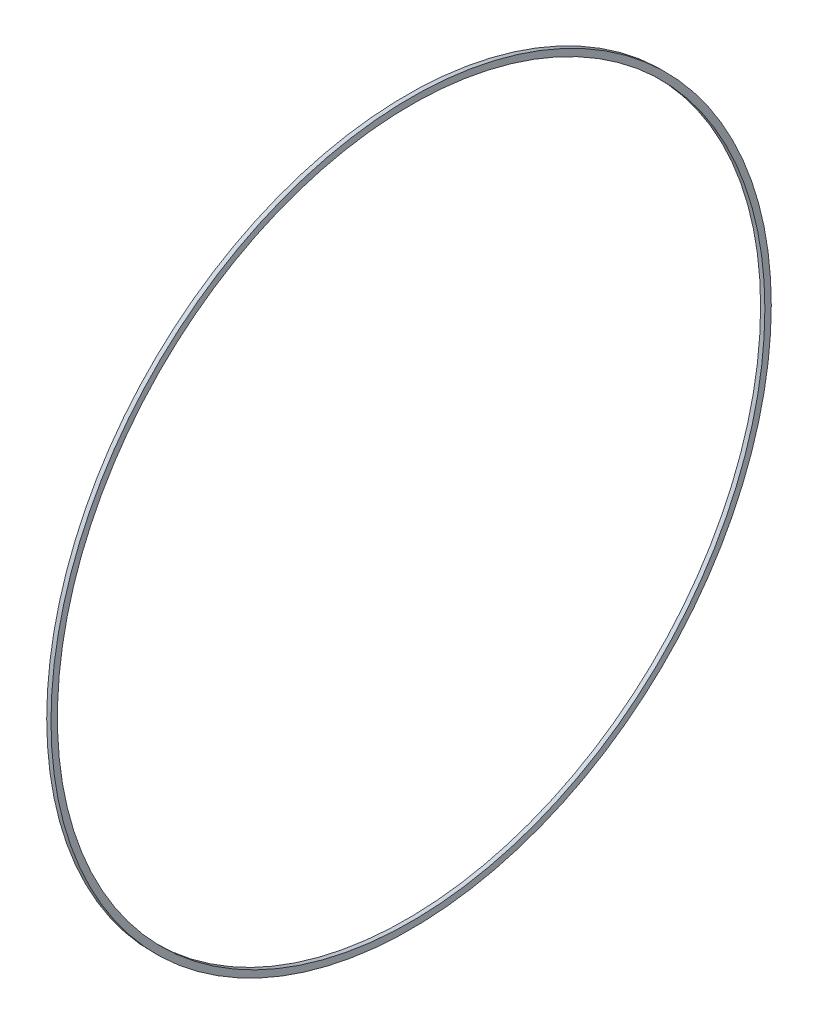
from build123d import *

# Parameters (mm, degrees)
SKETCH1_R           = 168.5
SKETCH1_R_2         = 165.5
BOSS_EXTRUDE1_DEPTH = 2


with BuildPart() as part:
    # Sketch1 → Boss-Extrude1 (new body)
    with BuildSketch(Plane(origin=(0, 0, 0), x_dir=(0, 0, -1), z_dir=(1, 0, 0))):
        Circle(SKETCH1_R)
        Circle(SKETCH1_R_2, mode=Mode.SUBTRACT)
    extrude(amount=BOSS_EXTRUDE1_DEPTH)


solid = part.part
